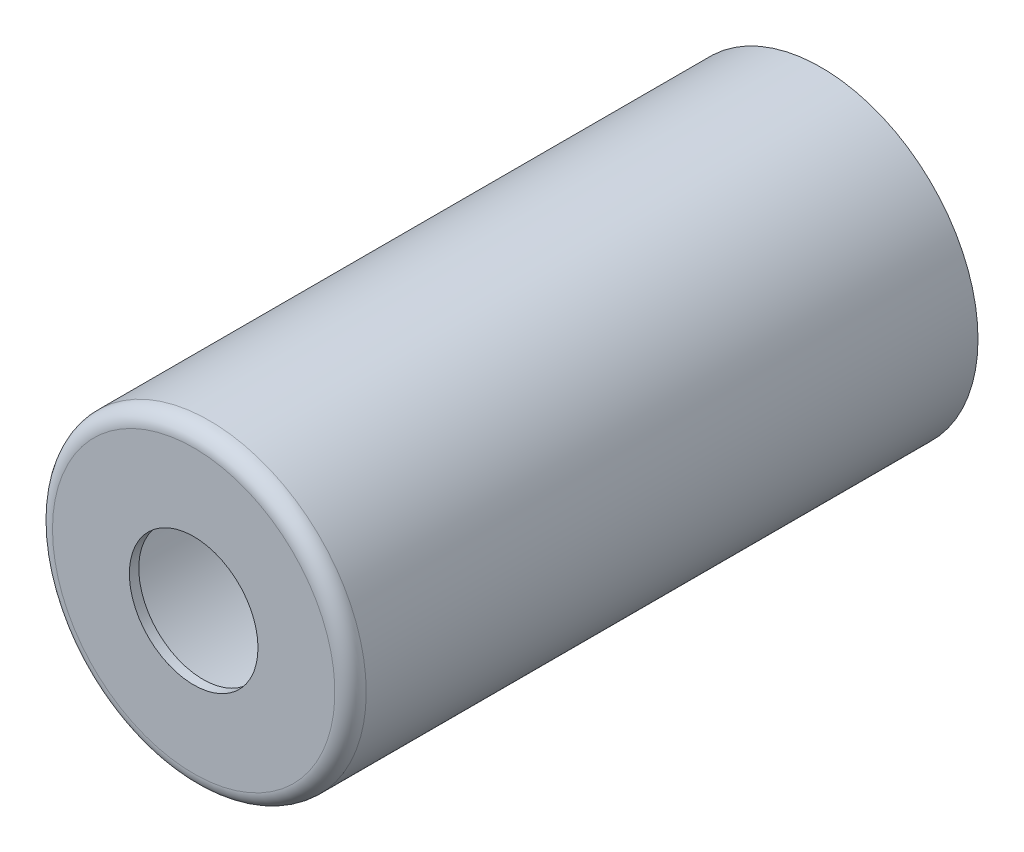
from build123d import *

# Parameters (mm, degrees)
FILLET_1_R = 5


with BuildPart() as part:
    # Эскиз1 → Повернуть1 (revolve)
    with BuildSketch(Plane(origin=(0, 0, 0), x_dir=(0, 0, -1), z_dir=(1, 0, 0))):
        Polygon((0, 50), (0, 20.5), (3, 20.5), (3, 47), (200, 47), (200, 50), align=None)
    revolve(axis=Axis((0, 0, 0), (0, 0, -1)))

    # Скругление1
    fillet_1_edges = [part.edges().sort_by_distance(p)[0] for p in [
        (0, -47, -3),
        (0, -50, 0),
    ]]
    fillet(fillet_1_edges, radius=FILLET_1_R)


solid = part.part
